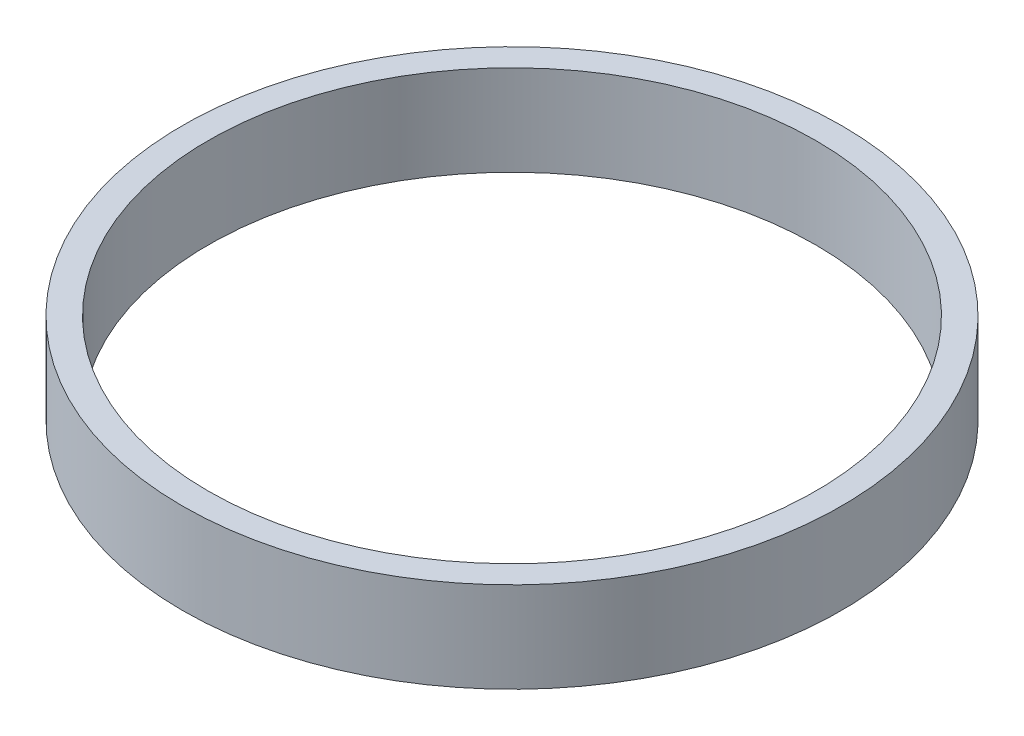
from build123d import *

# Parameters (mm, degrees)
SKETCH_1_R      = 25.5
SKETCH_1_R_2    = 23.5
EXTRUDE_1_DEPTH = 7


with BuildPart() as part:
    # 草图1 → 凸台-拉伸1 (new body)
    with BuildSketch(Plane(origin=(0, 0, 0), x_dir=(1, 0, 0), z_dir=(0, 1, 0))):
        Circle(SKETCH_1_R)
        Circle(SKETCH_1_R_2, mode=Mode.SUBTRACT)
    extrude(amount=EXTRUDE_1_DEPTH)


solid = part.part
